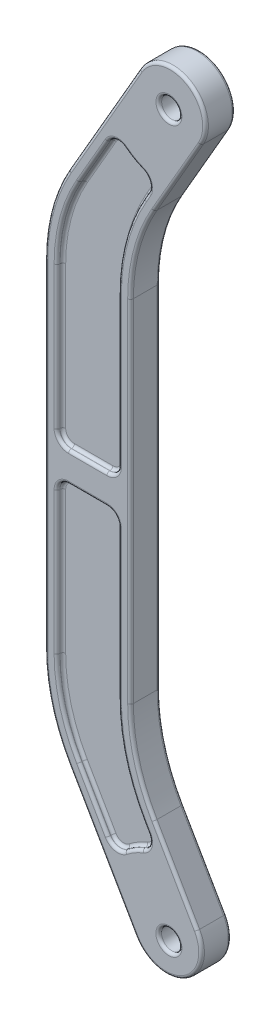
from build123d import *

# Parameters (mm, degrees)
EXTRUDE1_DEPTH      = 25
EXTRUDE1_DEPTH_BACK = 25
SKETCH3_R           = 17.13551903
SKETCH3_R_2         = 17.231991139
CUT_EXTRUDE1_DEPTH  = 10
CUT_EXTRUDE2_START  = -10
CUT_EXTRUDE2_DEPTH  = 10
FILLET1_R           = 4.826


with BuildPart() as part:
    # Sketch3 → Extrude1 (new, two sides: drawn at the far end of the back side and taken through both)
    with BuildSketch(Plane.XY.offset(-EXTRUDE1_DEPTH_BACK)):
        with BuildLine():
            Line((-24.807604607, 162.968065467), (47.382967486, 37.930316294))
            ThreePointArc((47.382967486, 37.930316294), (25.421440238, -44.031207308), (-56.540083363, -22.06968006))
            Line((-56.540083363, -22.06968006), (-169.807605742, 174.115435466))
            ThreePointArc((-169.807605742, 174.115435466), (-199.777732741, 246.469720642), (-209.99998495, 324.115433051))
            Line((-209.99998495, 324.115433051), (-209.99998495, 895.884583051))
            ThreePointArc((-209.99998495, 895.884583051), (-199.777733234, 973.530293564), (-169.807607648, 1045.884577221))
            Line((-169.807607648, 1045.884577221), (-49.82465968, 1253.701139142))
            ThreePointArc((-49.82465968, 1253.701139142), (32.136867624, 1275.662663595), (54.098392078, 1193.701136291))
            Line((54.098392078, 1193.701136291), (-24.807602614, 1057.031932005))
            ThreePointArc((-24.807602614, 1057.031932005), (-54.777728484, 984.677646375), (-64.999978983, 907.031933753))
            Line((-64.999978983, 907.031933753), (-64.999978983, 312.968053753))
            ThreePointArc((-64.999978983, 312.968053753), (-54.777728023, 235.322346461), (-24.807604607, 162.968065467))
        make_face()
        with Locations((0.048253388, 1219.998843051)):
            Circle(SKETCH3_R, mode=Mode.SUBTRACT)
        Circle(SKETCH3_R_2, mode=Mode.SUBTRACT)
    extrude(amount=EXTRUDE1_DEPTH + EXTRUDE1_DEPTH_BACK)

    # Sketch4 → Cut-Extrude1 (cut)
    with BuildSketch(Plane.XY.offset(25)):
        with BuildLine():
            Line((-85.317537612, 654.250003051), (-85.317530612, 907.031943051))
            ThreePointArc((-85.317530612, 907.031943051), (-74.402975126, 989.936220177), (-42.403118467, 1067.19070782))
            Line((-42.403118467, 1067.19070782), (-34.916014702, 1080.158771121))
            ThreePointArc((-34.916014702, 1080.158771121), (-33.363347921, 1096.442599596), (-44.656305727, 1108.276573903))
            ThreePointArc((-44.656305727, 1108.276573903), (-60.158769666, 1115.801958004), (-74.427174934, 1125.464794293))
            ThreePointArc((-74.427174934, 1125.464794293), (-90.322173256, 1129.327794011), (-103.648046289, 1119.841232651))
            Line((-103.648046289, 1119.841232651), (-152.212117713, 1035.725805096))
            ThreePointArc((-152.212117713, 1035.725805096), (-180.152510116, 968.271725823), (-189.682457612, 895.884583051))
            Line((-189.682457612, 895.884583051), (-189.682457612, 654.250003051))
            ThreePointArc((-189.682457612, 654.250003051), (-183.917598549, 640.332402114), (-169.999997612, 634.567543051))
            Line((-169.999997612, 634.567543051), (-104.999997612, 634.567543051))
            ThreePointArc((-104.999997612, 634.567543051), (-91.082396676, 640.332402114), (-85.317537612, 654.250003051))
        make_face()
        with BuildLine():
            Line((-152.212114349, 184.274207066), (-103.648045955, 100.158773186))
            ThreePointArc((-103.648045955, 100.158773186), (-90.322172483, 90.672211653), (-74.427173724, 94.535211517))
            ThreePointArc((-74.427173724, 94.535211517), (-60.158768087, 104.198048078), (-44.656303761, 111.723432429))
            ThreePointArc((-44.656303761, 111.723432429), (-33.363351675, 123.557400275), (-34.916017531, 139.841220175))
            Line((-34.916017531, 139.841220175), (-42.403127531, 152.809280175))
            ThreePointArc((-42.403127531, 152.809280175), (-74.402986959, 230.063776572), (-85.317541475, 312.968063051))
            Line((-85.317541475, 312.968063051), (-85.317541475, 564.750003051))
            ThreePointArc((-85.317541475, 564.750003051), (-91.082399138, 578.667600573), (-104.999996681, 584.432458189))
            Line((-104.999996681, 584.432458189), (-169.999996647, 584.432463051))
            ThreePointArc((-169.999996647, 584.432463051), (-183.917597561, 578.667603975), (-189.682456612, 564.750003051))
            Line((-189.682456612, 564.750003051), (-189.682456612, 324.115433051))
            ThreePointArc((-189.682456612, 324.115433051), (-180.152508504, 251.72828807), (-152.212114349, 184.274207066))
        make_face()
    extrude(amount=-CUT_EXTRUDE1_DEPTH, mode=Mode.SUBTRACT)

    # Sketch5 → Cut-Extrude2 (cut)
    with BuildSketch(Plane(origin=(0, 0, -25), x_dir=(-1, 0, 0), z_dir=(0, 0, -1)).offset(CUT_EXTRUDE2_START)):
        with BuildLine():
            Line((85.317530612, 907.031943051), (85.317537612, 654.250003051))
            ThreePointArc((85.317537612, 654.250003051), (91.082396676, 640.332402114), (104.999997612, 634.567543051))
            Line((104.999997612, 634.567543051), (169.999997612, 634.567543051))
            ThreePointArc((169.999997612, 634.567543051), (183.917598549, 640.332402114), (189.682457612, 654.250003051))
            Line((189.682457612, 654.250003051), (189.682457612, 895.884583051))
            ThreePointArc((189.682457612, 895.884583051), (180.152510116, 968.271725823), (152.212117713, 1035.725805096))
            Line((152.212117713, 1035.725805096), (103.648046289, 1119.841232651))
            ThreePointArc((103.648046289, 1119.841232651), (90.322173256, 1129.327794011), (74.427174934, 1125.464794293))
            ThreePointArc((74.427174934, 1125.464794293), (60.158769666, 1115.801958004), (44.656305727, 1108.276573903))
            ThreePointArc((44.656305727, 1108.276573903), (33.363347921, 1096.442599596), (34.916014702, 1080.158771121))
            Line((34.916014702, 1080.158771121), (42.403118467, 1067.19070782))
            ThreePointArc((42.403118467, 1067.19070782), (74.402975126, 989.936220177), (85.317530612, 907.031943051))
        make_face()
        with BuildLine():
            Line((103.648045955, 100.158773186), (152.212114349, 184.274207066))
            ThreePointArc((152.212114349, 184.274207066), (180.152508504, 251.72828807), (189.682456612, 324.115433051))
            Line((189.682456612, 324.115433051), (189.682456612, 564.750003051))
            ThreePointArc((189.682456612, 564.750003051), (183.917597561, 578.667603975), (169.999996647, 584.432463051))
            Line((169.999996647, 584.432463051), (104.999996681, 584.432458189))
            ThreePointArc((104.999996681, 584.432458189), (91.082399138, 578.667600573), (85.317541475, 564.750003051))
            Line((85.317541475, 564.750003051), (85.317541475, 312.968063051))
            ThreePointArc((85.317541475, 312.968063051), (74.402986959, 230.063776572), (42.403127531, 152.809280175))
            Line((42.403127531, 152.809280175), (34.916017531, 139.841220175))
            ThreePointArc((34.916017531, 139.841220175), (33.363351675, 123.557400275), (44.656303761, 111.723432429))
            ThreePointArc((44.656303761, 111.723432429), (60.158768087, 104.198048078), (74.427173724, 94.535211517))
            ThreePointArc((74.427173724, 94.535211517), (90.322172483, 90.672211653), (103.648045955, 100.158773186))
        make_face()
    extrude(amount=CUT_EXTRUDE2_DEPTH, mode=Mode.SUBTRACT)

    # Fillet1
    fillet1_edges = [part.edges().sort_by_distance(p)[0] for p in [
        (-189.682456612, 444.432718051, 15),
        (-183.917597561, 578.667603975, 15),
        (-137.499996664, 584.43246062, 15),
        (-91.082399138, 578.667600573, 15),
        (-85.317541475, 438.859033051, 15),
        (-74.402986959, 230.063776572, 15),
        (-38.659572531, 146.325250175, 15),
        (-33.363351675, 123.557400275, 15),
        (-60.158768087, 104.198048078, 15),
        (-90.322172483, 90.672211653, 15),
        (-127.930080152, 142.216490126, 15),
        (-180.152508504, 251.72828807, 15),
        (-17.231991139, 0, 25),
        (-113.173844553, 76.022877703, 25),
        (-199.777732741, 246.469720642, 25),
        (-209.99998495, 610.000008051, 25),
        (-199.777733234, 973.530293564, 25),
        (-109.816133664, 1149.792858181, 25),
        (32.136867624, 1275.662663595, 25),
        (14.645394732, 1125.366534148, 25),
        (-54.777728484, 984.677646375, 25),
        (-64.999978983, 609.999993753, 25),
        (-54.777728023, 235.322346461, 25),
        (11.28768144, 100.44919088, 25),
        (25.421440238, -44.031207308, 25),
        (-17.087265643, 1219.998843051, 25),
        (-85.317534112, 780.640973051, 25),
        (-74.402975126, 989.936220177, 25),
        (-38.659566585, 1073.67473947, 25),
        (-33.363347921, 1096.442599596, 25),
        (-60.158769666, 1115.801958004, 25),
        (-90.322173256, 1129.327794011, 25),
        (-127.930082001, 1077.783518873, 25),
        (-180.152510116, 968.271725823, 25),
        (-189.682457612, 775.067293051, 25),
        (-183.917598549, 640.332402114, 25),
        (-137.499997612, 634.567543051, 25),
        (-91.082396676, 640.332402114, 25),
        (-127.930080152, 142.216490126, 25),
        (-90.322172483, 90.672211653, 25),
        (-60.158768087, 104.198048078, 25),
        (-33.363351675, 123.557400275, 25),
        (-38.659572531, 146.325250175, 25),
        (-74.402986959, 230.063776572, 25),
        (-85.317541475, 438.859033051, 25),
        (-91.082399138, 578.667600573, 25),
        (-137.499996664, 584.43246062, 25),
        (-183.917597561, 578.667603975, 25),
        (-189.682456612, 444.432718051, 25),
        (-180.152508504, 251.72828807, 25),
        (-137.499997612, 634.567543051, 15),
        (-183.917598549, 640.332402114, 15),
        (-189.682457612, 775.067293051, 15),
        (-180.152510116, 968.271725823, 15),
        (-127.930082001, 1077.783518873, 15),
        (-90.322173256, 1129.327794011, 15),
        (-60.158769666, 1115.801958004, 15),
        (-33.363347921, 1096.442599596, 15),
        (-38.659566585, 1073.67473947, 15),
        (-74.402975126, 989.936220177, 15),
        (-85.317534112, 780.640973051, 15),
        (-91.082396676, 640.332402114, 15),
        (-85.317534112, 780.640973051, -15),
        (-74.402975126, 989.936220177, -15),
        (-38.659566585, 1073.67473947, -15),
        (-33.363347921, 1096.442599596, -15),
        (-60.158769666, 1115.801958004, -15),
        (-90.322173256, 1129.327794011, -15),
        (-127.930082001, 1077.783518873, -15),
        (-180.152510116, 968.271725823, -15),
        (-189.682457612, 775.067293051, -15),
        (-183.917598549, 640.332402114, -15),
        (-137.499997612, 634.567543051, -15),
        (-91.082396676, 640.332402114, -15),
        (11.28768144, 100.44919088, -25),
        (-54.777728023, 235.322346461, -25),
        (-64.999978983, 609.999993753, -25),
        (-54.777728484, 984.677646375, -25),
        (14.645394732, 1125.366534148, -25),
        (32.136867624, 1275.662663595, -25),
        (-109.816133664, 1149.792858181, -25),
        (-199.777733234, 973.530293564, -25),
        (-209.99998495, 610.000008051, -25),
        (-199.777732741, 246.469720642, -25),
        (-113.173844553, 76.022877703, -25),
        (25.421440238, -44.031207308, -25),
        (-17.087265643, 1219.998843051, -25),
        (-17.231991139, 0, -25),
        (-183.917598549, 640.332402114, -25),
        (-189.682457612, 775.067293051, -25),
        (-180.152510116, 968.271725823, -25),
        (-127.930082001, 1077.783518873, -25),
        (-90.322173256, 1129.327794011, -25),
        (-60.158769666, 1115.801958004, -25),
        (-33.363347921, 1096.442599596, -25),
        (-38.659566585, 1073.67473947, -25),
        (-74.402975126, 989.936220177, -25),
        (-85.317534112, 780.640973051, -25),
        (-91.082396676, 640.332402114, -25),
        (-137.499997612, 634.567543051, -25),
        (-183.917597561, 578.667603975, -25),
        (-137.499996664, 584.43246062, -25),
        (-91.082399138, 578.667600573, -25),
        (-85.317541475, 438.859033051, -25),
        (-74.402986959, 230.063776572, -25),
        (-38.659572531, 146.325250175, -25),
        (-33.363351675, 123.557400275, -25),
        (-60.158768087, 104.198048078, -25),
        (-90.322172483, 90.672211653, -25),
        (-127.930080152, 142.216490126, -25),
        (-180.152508504, 251.72828807, -25),
        (-189.682456612, 444.432718051, -25),
        (-127.930080152, 142.216490126, -15),
        (-90.322172483, 90.672211653, -15),
        (-60.158768087, 104.198048078, -15),
        (-33.363351675, 123.557400275, -15),
        (-38.659572531, 146.325250175, -15),
        (-74.402986959, 230.063776572, -15),
        (-85.317541475, 438.859033051, -15),
        (-91.082399138, 578.667600573, -15),
        (-137.499996664, 584.43246062, -15),
        (-183.917597561, 578.667603975, -15),
        (-189.682456612, 444.432718051, -15),
        (-180.152508504, 251.72828807, -15),
    ]]
    fillet(fillet1_edges, radius=FILLET1_R)


solid = part.part
